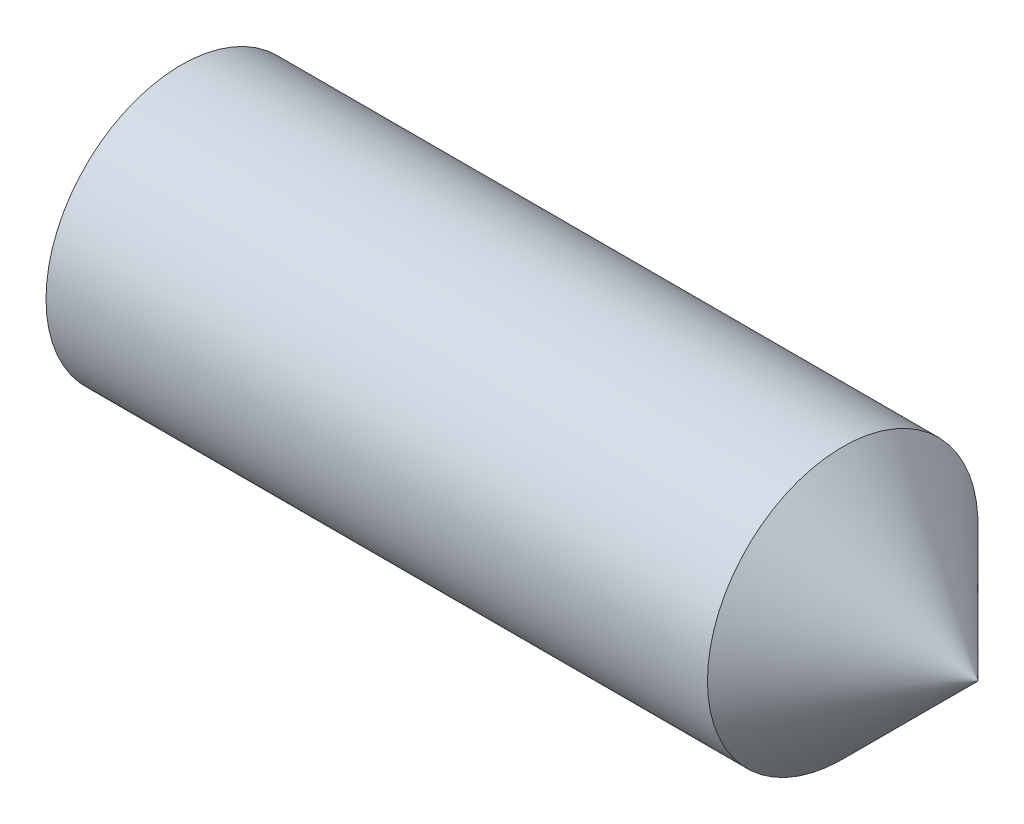
from build123d import *

# Parameters (mm, degrees)
HEX_2_DEPTH = 2.5


with BuildPart() as part:
    # BodySke → BaseBody (revolve)
    with BuildSketch(Plane.XY):
        Polygon((0, 0), (0, 1.61), (0.225166605, 2), (10.005, 2), (12, 0.005), (12, 0), align=None)
    revolve(axis=Axis((-12.7, 0, 0), (1, 0, 0)))

    # Sketch2 → Hex 2 (cut)
    with BuildSketch(Plane.ZY):
        Polygon((0.577350269, 1), (-0.577350269, 1), (-1.154700538, 0), (-0.577350269, -1), (0.577350269, -1), (1.154700538, 0), align=None)
    extrude(amount=-HEX_2_DEPTH, mode=Mode.SUBTRACT)


solid = part.part
